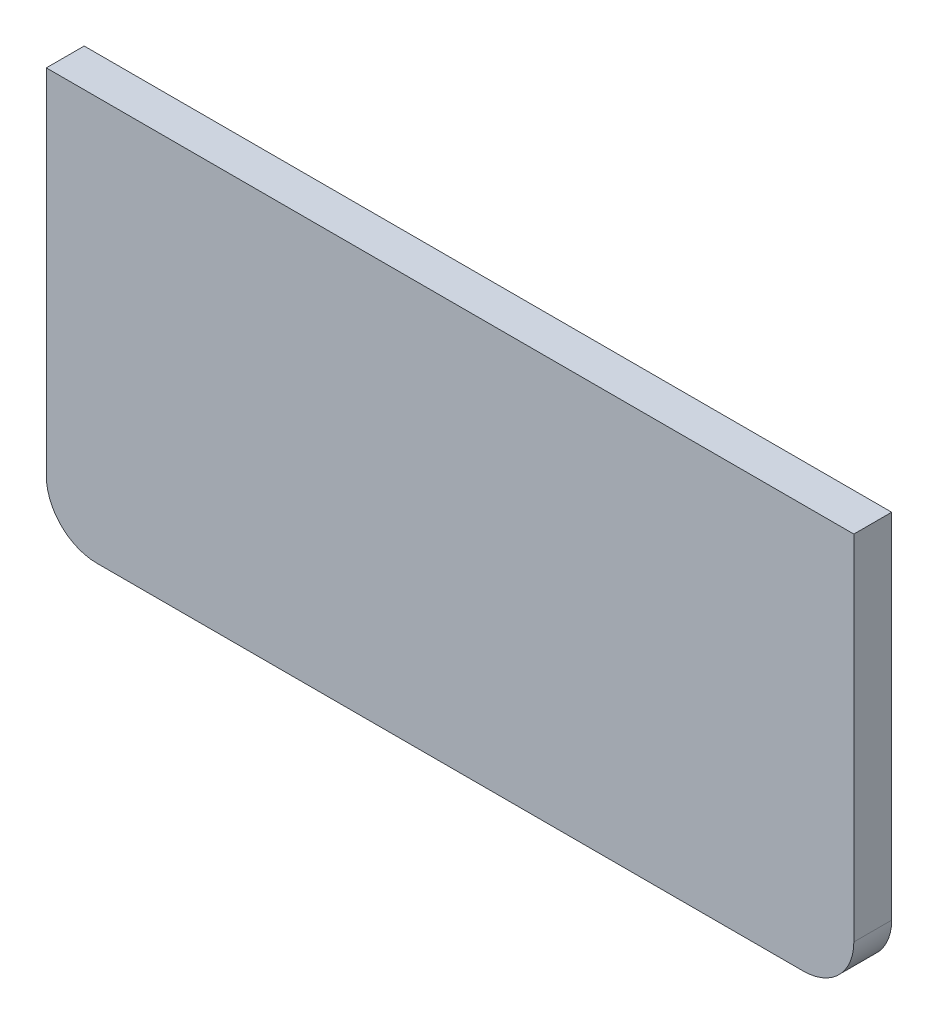
from build123d import *

# Parameters (mm, degrees)
SKETCH1_W           = 203.2
SKETCH1_H           = 101.6
BOSS_EXTRUDE1_DEPTH = 4.7625
FILLET1_R           = 12.7


with BuildPart() as part:
    # Sketch1 → Boss-Extrude1 (new body, symmetric)
    with BuildSketch(Plane.XY):
        Rectangle(SKETCH1_W, SKETCH1_H)
    extrude(amount=BOSS_EXTRUDE1_DEPTH, both=True)

    # Fillet1
    fillet1_edges = [part.edges().sort_by_distance(p)[0] for p in [
        (101.6, -50.8, 0),
        (-101.6, -50.8, 0),
    ]]
    fillet(fillet1_edges, radius=FILLET1_R)


solid = part.part
